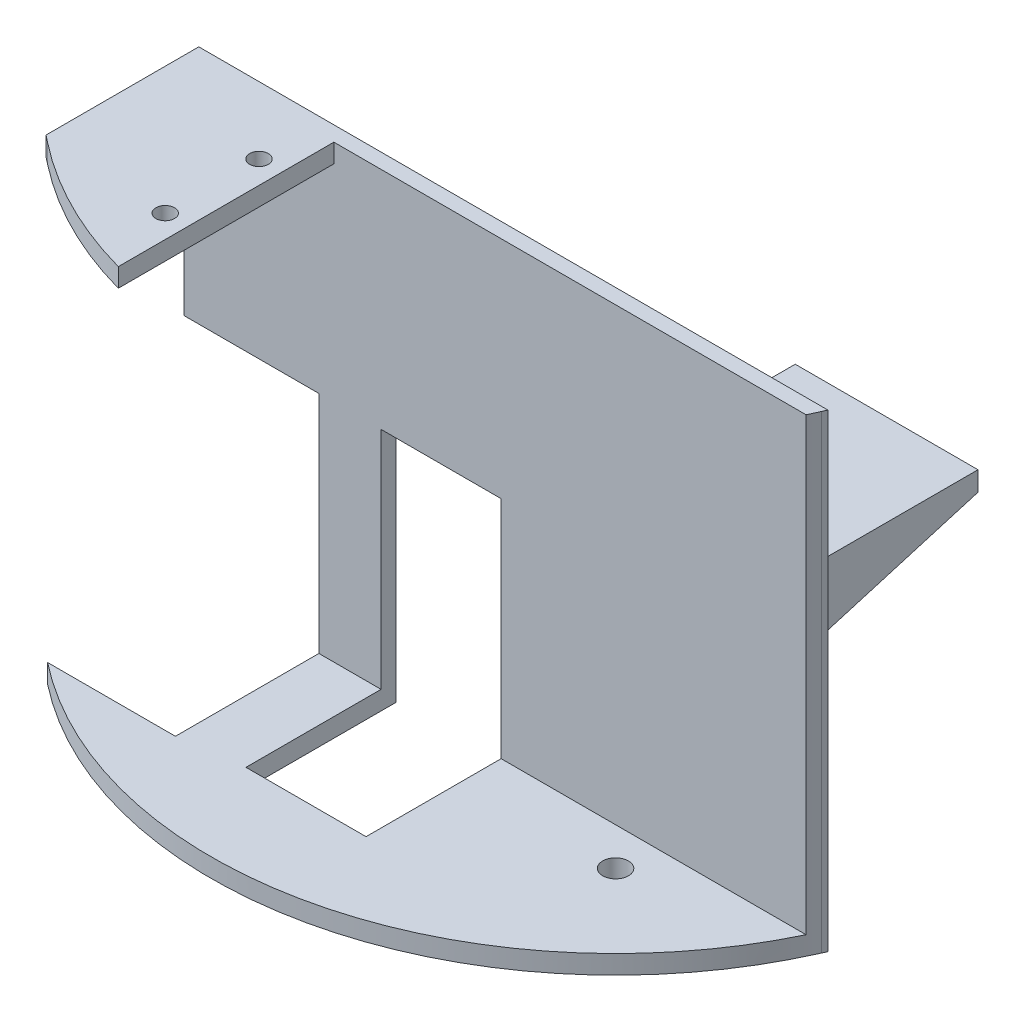
from build123d import *

# Parameters (mm, degrees)
SKETCH1_R               = 5.357495
SKETCH1_R_2             = 2.182495
RAISER_DEPTH            = 4.7625
RAISER_2_DEPTH          = 4.7625
SKETCH3_R               = 2.182495
PLATFORM_DEPTH          = 3.175
WALLS_DEPTH             = 76.2
SKETCH9_W               = 31.75
SKETCH9_H               = 3.302
BOSS_EXTRUDE4_DEPTH     = 25.4
BOSS_EXTRUDE5_DEPTH     = 31.75
BOSS_EXTRUDE6_DEPTH     = 3.175
SKETCH13_R              = 1.585905821
CUT_EXTRUDE1_DEPTH      = 3.175
SKETCH14_W              = 22.86
SKETCH14_H              = 38.1
CUT_EXTRUDE2_DEPTH      = 2.54
SKETCH16_W              = 22.86
SKETCH16_H              = 26.817011057
CUT_EXTRUDE3_DEPTH      = 5080
SKETCH17_W              = 20.32
SKETCH17_H              = 38.1
CUT_EXTRUDE4_DEPTH      = 2.54
SKETCH18_W              = 20.32
SKETCH18_H              = 25.4
CUT_EXTRUDE5_DEPTH      = 8.9375
SKETCH21_R              = 23.434999297
CUT_EXTRUDE6_DEPTH      = 5.7625
CUT_EXTRUDE7_DEPTH      = 77.2
CUT_EXTRUDE7_DEPTH_BACK = 4.175
SKETCH23_W              = 0.822798121
SKETCH23_H              = 25.4
CUT_EXTRUDE8_DEPTH      = 22.448562342
CUT_EXTRUDE8_DEPTH_BACK = 58.926437658
CUT_EXTRUDE9_DEPTH      = 1
CUT_EXTRUDE9_DEPTH_BACK = 80.375


with BuildPart() as part:
    # Sketch1 → Raiser (new body)
    with BuildSketch(Plane(origin=(0, 0, 0), x_dir=(1, 0, 0), z_dir=(0, 1, 0))):
        with Locations((-24.991443565, 0)):
            Circle(SKETCH1_R)
        with Locations((-24.991443565, 0)):
            Circle(SKETCH1_R_2, mode=Mode.SUBTRACT)
    extrude(amount=RAISER_DEPTH)



with BuildPart() as body_2:
    # Sketch1 → Raiser 2 (new body)
    with BuildSketch(Plane(origin=(0, 0, 0), x_dir=(1, 0, 0), z_dir=(0, 1, 0))):
        with Locations((46.849916435, 0)):
            Circle(SKETCH1_R)
        with Locations((46.849916435, 0)):
            Circle(SKETCH1_R_2, mode=Mode.SUBTRACT)
    extrude(amount=RAISER_2_DEPTH)


with BuildPart() as part_1:
    add(part.part)

    add(body_2.part)  # Platform merges body 2
    # Sketch3 → Platform (add)
    with BuildSketch(Plane(origin=(0, 4.7625, 0), x_dir=(1, 0, 0), z_dir=(0, 1, 0))):
        with BuildLine():
            Line((-32.611443565, 8.933868965), (-32.611443565, -17.883142092))
            ThreePointArc((-32.611443565, -17.883142092), (27.714936864, -31.227394881), (74.666125822, 8.933868965))
            Line((74.666125822, 8.933868965), (-32.611443565, 8.933868965))
        make_face()
        with Locations((-24.991443565, 0)):
            Circle(SKETCH3_R, mode=Mode.SUBTRACT)
        with Locations((46.849916435, 0)):
            Circle(SKETCH3_R, mode=Mode.SUBTRACT)
    extrude(amount=PLATFORM_DEPTH)

    # Sketch7 → Walls (add)
    with BuildSketch(Plane(origin=(0, 7.9375, 0), x_dir=(1, 0, 0), z_dir=(0, 1, 0))):
        with BuildLine():
            Line((74.666125822, 8.933868965), (-32.611443565, 8.933868965))
            Line((-32.611443565, 8.933868965), (-32.611443565, 6.393868965))
            Line((-32.611443565, 6.393868965), (-30.071443565, 6.393868965))
            Line((-30.071443565, 6.393868965), (73.529899121, 6.393868965))
            ThreePointArc((73.529899121, 6.393868965), (74.110777774, 7.65815862), (74.666125822, 8.933868965))
        make_face()
    extrude(amount=WALLS_DEPTH)

    # Sketch9 → Boss-Extrude4 (add)
    with BuildSketch(Plane(origin=(0, 0, -8.933868965), x_dir=(-1, 0, 0), z_dir=(0, 0, -1))):
        with Locations((-58.791125822, 61.037937658)):
            Rectangle(SKETCH9_W, SKETCH9_H)
    extrude(amount=BOSS_EXTRUDE4_DEPTH)

    # Sketch10 → Boss-Extrude5 (add)
    with BuildSketch(Plane.ZY.offset(-42.916125822)):
        Polygon((-34.333868965, 59.386937658), (-8.933868965, 51.890363409), (-8.933868965, 59.386937658), align=None)
    extrude(amount=-BOSS_EXTRUDE5_DEPTH)

    # Sketch12 → Boss-Extrude6 (add)
    with BuildSketch(Plane(origin=(0, 84.1375, 0), x_dir=(1, 0, 0), z_dir=(0, 1, 0))):
        with BuildLine():
            Line((-32.611443565, 6.393868965), (-32.611443565, -17.883142092))
            ThreePointArc((-32.611443565, -17.883142092), (-20.588039105, -25.701496657), (-7.211443565, -30.874079638))
            Line((-7.211443565, -30.874079638), (-7.211443565, 6.393868965))
            Line((-7.211443565, 6.393868965), (-32.611443565, 6.393868965))
        make_face()
    extrude(amount=-BOSS_EXTRUDE6_DEPTH)

    # Sketch13 → Cut-Extrude1 (cut)
    with BuildSketch(Plane(origin=(0, 84.1375, 0), x_dir=(1, 0, 0), z_dir=(0, 1, 0))):
        with Locations((-11.081791728, -2.408517057)):
            Circle(SKETCH13_R)
        with Locations((-11.081791728, -18.283517057)):
            Circle(SKETCH13_R)
    extrude(amount=-CUT_EXTRUDE1_DEPTH, mode=Mode.SUBTRACT)

    # Sketch14 → Cut-Extrude2 (cut)
    with BuildSketch(Plane.XY.offset(-6.393868965)):
        with Locations((-21.181443565, 26.9875)):
            Rectangle(SKETCH14_W, SKETCH14_H)
    extrude(amount=-CUT_EXTRUDE2_DEPTH, mode=Mode.SUBTRACT)

    # Sketch16 → Cut-Extrude3 (cut)
    with BuildSketch(Plane(origin=(0, 7.9375, 0), x_dir=(1, 0, 0), z_dir=(0, 1, 0))):
        with Locations((-21.181443565, -4.474636563)):
            Rectangle(SKETCH16_W, SKETCH16_H)
    extrude(amount=-CUT_EXTRUDE3_DEPTH, mode=Mode.SUBTRACT)

    # Sketch17 → Cut-Extrude4 (cut)
    with BuildSketch(Plane.XY.offset(-6.393868965)):
        with Locations((10.929236435, 26.9875)):
            Rectangle(SKETCH17_W, SKETCH17_H)
    extrude(amount=-CUT_EXTRUDE4_DEPTH, mode=Mode.SUBTRACT)

    # Sketch18 → Cut-Extrude5 (cut, through all)
    with BuildSketch(Plane(origin=(0, 7.9375, 0), x_dir=(1, 0, 0), z_dir=(0, 1, 0))):
        with Locations((10.929236435, -3.766131035)):
            Rectangle(SKETCH18_W, SKETCH18_H)
    extrude(amount=-CUT_EXTRUDE5_DEPTH, mode=Mode.SUBTRACT)

    # Sketch21 → Cut-Extrude6 (cut, through all)
    with BuildSketch(Plane.XZ.offset(-4.7625)):
        with Locations((35.627803811, 7.157128957)):
            Circle(SKETCH21_R)
    extrude(amount=CUT_EXTRUDE6_DEPTH, mode=Mode.SUBTRACT)

    # Sketch22 → Cut-Extrude7 (cut, two sides)
    with BuildSketch(Plane(origin=(0, 7.9375, 0), x_dir=(1, 0, 0), z_dir=(0, 1, 0))) as cut_extrude7_sk:
        with BuildLine():
            ThreePointArc((72.686340907, 6.393868965), (26.479298711, -30.742030079), (-31.389645862, -17.883142092))
            Line((-31.389645862, -17.883142092), (-32.611443565, -17.883142092))
            ThreePointArc((-32.611443565, -17.883142092), (26.361801078, -31.551234168), (73.529899121, 6.393868965))
            Line((73.529899121, 6.393868965), (72.686340907, 6.393868965))
        make_face()
        with BuildLine():
            ThreePointArc((73.505417676, 8.171868965), (73.102235438, 7.279940859), (72.686340907, 6.393868965))
            Line((72.686340907, 6.393868965), (73.529899121, 6.393868965))
            ThreePointArc((73.529899121, 6.393868965), (74.110777774, 7.65815862), (74.666125822, 8.933868965))
            Line((74.666125822, 8.933868965), (73.843327701, 8.933868965))
            Line((73.843327701, 8.933868965), (73.505417676, 8.171868965))
        make_face()
    extrude(amount=CUT_EXTRUDE7_DEPTH, mode=Mode.SUBTRACT)
    extrude(cut_extrude7_sk.sketch, amount=-CUT_EXTRUDE7_DEPTH_BACK, mode=Mode.SUBTRACT)

    # Sketch23 → Cut-Extrude8 (cut, two sides)
    with BuildSketch(Plane(origin=(0, 62.688937658, 0), x_dir=(1, 0, 0), z_dir=(0, 1, 0))) as cut_extrude8_sk:
        with Locations((74.254726761, 21.633868965)):
            Rectangle(SKETCH23_W, SKETCH23_H)
    extrude(amount=CUT_EXTRUDE8_DEPTH, mode=Mode.SUBTRACT)
    extrude(cut_extrude8_sk.sketch, amount=-CUT_EXTRUDE8_DEPTH_BACK, mode=Mode.SUBTRACT)

    # Sketch24 → Cut-Extrude9 (cut, two sides)
    with BuildSketch(Plane(origin=(0, 84.1375, 0), x_dir=(1, 0, 0), z_dir=(0, 1, 0))) as cut_extrude9_sk:
        Polygon((-32.611443565, -16.922161086), (-32.611443565, -17.883142092), (-31.389645862, -17.883142092), align=None)
    extrude(amount=CUT_EXTRUDE9_DEPTH, mode=Mode.SUBTRACT)
    extrude(cut_extrude9_sk.sketch, amount=-CUT_EXTRUDE9_DEPTH_BACK, mode=Mode.SUBTRACT)


solid = part_1.part
